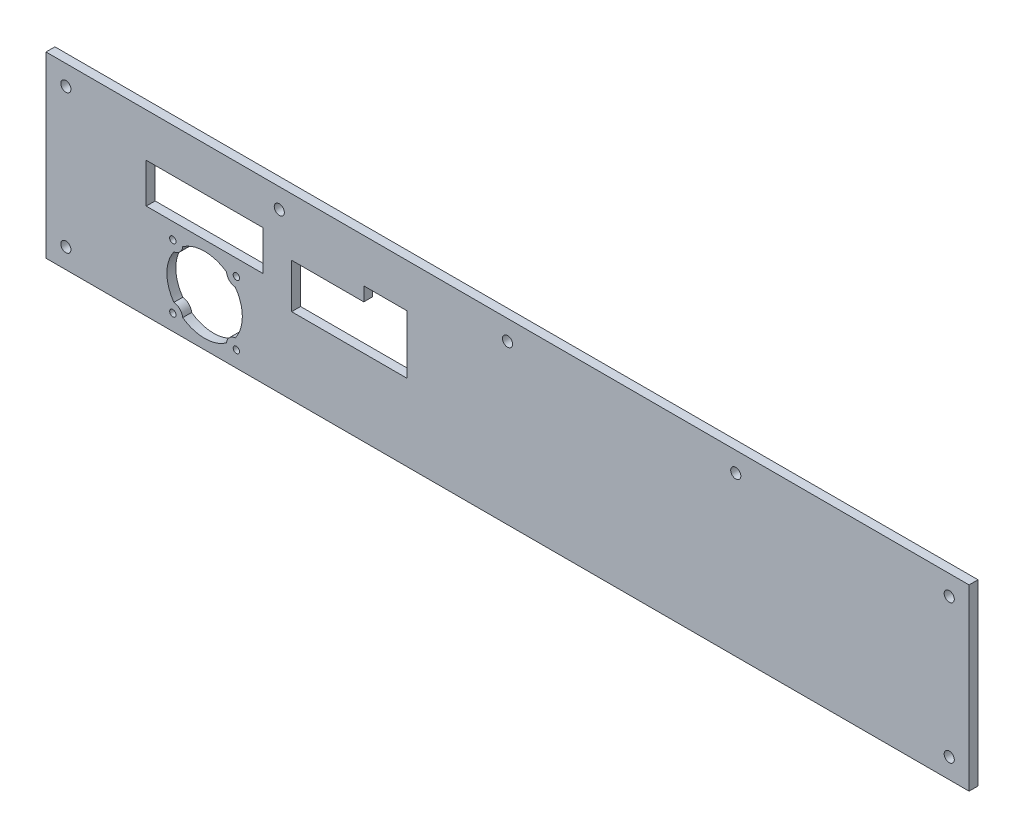
from build123d import *

# Parameters (mm, degrees)
SKETCH1_W           = 465
SKETCH1_H           = 90
SKETCH1_R           = 2.55
BOSS_EXTRUDE1_DEPTH = 2.2479
CUT_EXTRUDE1_REACH  = 6.496
SKETCH2_R           = 1.6
SKETCH2_W           = 58.8
SKETCH2_H           = 20


with BuildPart() as part:
    # Sketch1 → Boss-Extrude1 (new body, symmetric)
    with BuildSketch(Plane.XY):
        Rectangle(SKETCH1_W, SKETCH1_H)
        with Locations((-222.5, 35)):
            Circle(SKETCH1_R, mode=Mode.SUBTRACT)
        with Locations((-222.5, -35)):
            Circle(SKETCH1_R, mode=Mode.SUBTRACT)
        with Locations((0, 35)):
            Circle(SKETCH1_R, mode=Mode.SUBTRACT)
        with Locations((-114.975, 35)):
            Circle(SKETCH1_R, mode=Mode.SUBTRACT)
        with Locations((222.5, -35)):
            Circle(SKETCH1_R, mode=Mode.SUBTRACT)
        with Locations((222.5, 35)):
            Circle(SKETCH1_R, mode=Mode.SUBTRACT)
        with Locations((114.975, 35)):
            Circle(SKETCH1_R, mode=Mode.SUBTRACT)
    extrude(amount=BOSS_EXTRUDE1_DEPTH, both=True)

    # Sketch2 → Cut-Extrude1 (cut, up to next)
    with BuildSketch(Plane.XY.offset(2.2479), mode=Mode.PRIVATE) as cut_extrude1_sk1:
        with Locations((-136.600006438, -5)):
            Circle(SKETCH2_R)
    cut_extrude1_tool1 = extrude(cut_extrude1_sk1.sketch, amount=-CUT_EXTRUDE1_REACH, mode=Mode.PRIVATE) & part.part
    add(cut_extrude1_tool1.solids().sort_by_distance((-136.600006, -5, 2.2479))[0], mode=Mode.SUBTRACT)
    # Sketch2 → Cut-Extrude1 (cut, up to next)
    with BuildSketch(Plane.XY.offset(2.2479), mode=Mode.PRIVATE) as cut_extrude1_sk2:
        with Locations((-168.600006438, -5)):
            Circle(SKETCH2_R)
    cut_extrude1_tool2 = extrude(cut_extrude1_sk2.sketch, amount=-CUT_EXTRUDE1_REACH, mode=Mode.PRIVATE) & part.part
    add(cut_extrude1_tool2.solids().sort_by_distance((-168.600006, -5, 2.2479))[0], mode=Mode.SUBTRACT)
    # Sketch2 → Cut-Extrude1 (cut, up to next)
    with BuildSketch(Plane.XY.offset(2.2479), mode=Mode.PRIVATE) as cut_extrude1_sk3:
        with Locations((-168.600006438, -37)):
            Circle(SKETCH2_R)
    cut_extrude1_tool3 = extrude(cut_extrude1_sk3.sketch, amount=-CUT_EXTRUDE1_REACH, mode=Mode.PRIVATE) & part.part
    add(cut_extrude1_tool3.solids().sort_by_distance((-168.600006, -37, 2.2479))[0], mode=Mode.SUBTRACT)
    # Sketch2 → Cut-Extrude1 (cut, up to next)
    with BuildSketch(Plane.XY.offset(2.2479), mode=Mode.PRIVATE) as cut_extrude1_sk4:
        with Locations((-136.600006438, -37)):
            Circle(SKETCH2_R)
    cut_extrude1_tool4 = extrude(cut_extrude1_sk4.sketch, amount=-CUT_EXTRUDE1_REACH, mode=Mode.PRIVATE) & part.part
    add(cut_extrude1_tool4.solids().sort_by_distance((-136.600006, -37, 2.2479))[0], mode=Mode.SUBTRACT)
    # Sketch2 → Cut-Extrude1 (cut, up to next)
    with BuildSketch(Plane.XY.offset(2.2479), mode=Mode.PRIVATE) as cut_extrude1_sk5:
        Polygon((-108.747160909, 16), (-72.422339974, 16), (-72.422339974, 23), (-50.542339974, 23), (-50.542339974, -6.43), (-108.747160909, -6.43), align=None)
    cut_extrude1_tool5 = extrude(cut_extrude1_sk5.sketch, amount=-CUT_EXTRUDE1_REACH, mode=Mode.PRIVATE) & part.part
    add(cut_extrude1_tool5.solids().sort_by_distance((-77.737733, 6.330046, 2.2479))[0], mode=Mode.SUBTRACT)
    # Sketch2 → Cut-Extrude1 (cut, up to next)
    with BuildSketch(Plane.XY.offset(2.2479), mode=Mode.PRIVATE) as cut_extrude1_sk6:
        with Locations((-152.600006438, 13)):
            Rectangle(SKETCH2_W, SKETCH2_H)
    cut_extrude1_tool6 = extrude(cut_extrude1_sk6.sketch, amount=-CUT_EXTRUDE1_REACH, mode=Mode.PRIVATE) & part.part
    add(cut_extrude1_tool6.solids().sort_by_distance((-152.600006, 13, 2.2479))[0], mode=Mode.SUBTRACT)
    # Sketch2 → Cut-Extrude1 (cut, up to next)
    with BuildSketch(Plane.XY.offset(2.2479), mode=Mode.PRIVATE) as cut_extrude1_sk7:
        with BuildLine():
            ThreePointArc((-163.627957833, -36.472048604), (-152.600006438, -40), (-141.572055042, -36.472048604))
            ThreePointArc((-141.572055042, -36.472048604), (-140.135540343, -33.464466094), (-137.127957833, -32.027951396))
            ThreePointArc((-137.127957833, -32.027951396), (-133.600006437, -21), (-137.127957833, -9.972048604))
            ThreePointArc((-137.127957833, -9.972048604), (-140.135540343, -8.535533906), (-141.572055042, -5.527951396))
            ThreePointArc((-141.572055042, -5.527951396), (-152.600006438, -2), (-163.627957833, -5.527951396))
            ThreePointArc((-163.627957833, -5.527951396), (-165.064472532, -8.535533906), (-168.072055042, -9.972048604))
            ThreePointArc((-168.072055042, -9.972048604), (-171.600006437, -21), (-168.072055042, -32.027951396))
            ThreePointArc((-168.072055042, -32.027951396), (-165.064472532, -33.464466094), (-163.627957833, -36.472048604))
        make_face()
    cut_extrude1_tool7 = extrude(cut_extrude1_sk7.sketch, amount=-CUT_EXTRUDE1_REACH, mode=Mode.PRIVATE) & part.part
    add(cut_extrude1_tool7.solids().sort_by_distance((-152.600006, -21, 2.2479))[0], mode=Mode.SUBTRACT)


solid = part.part
